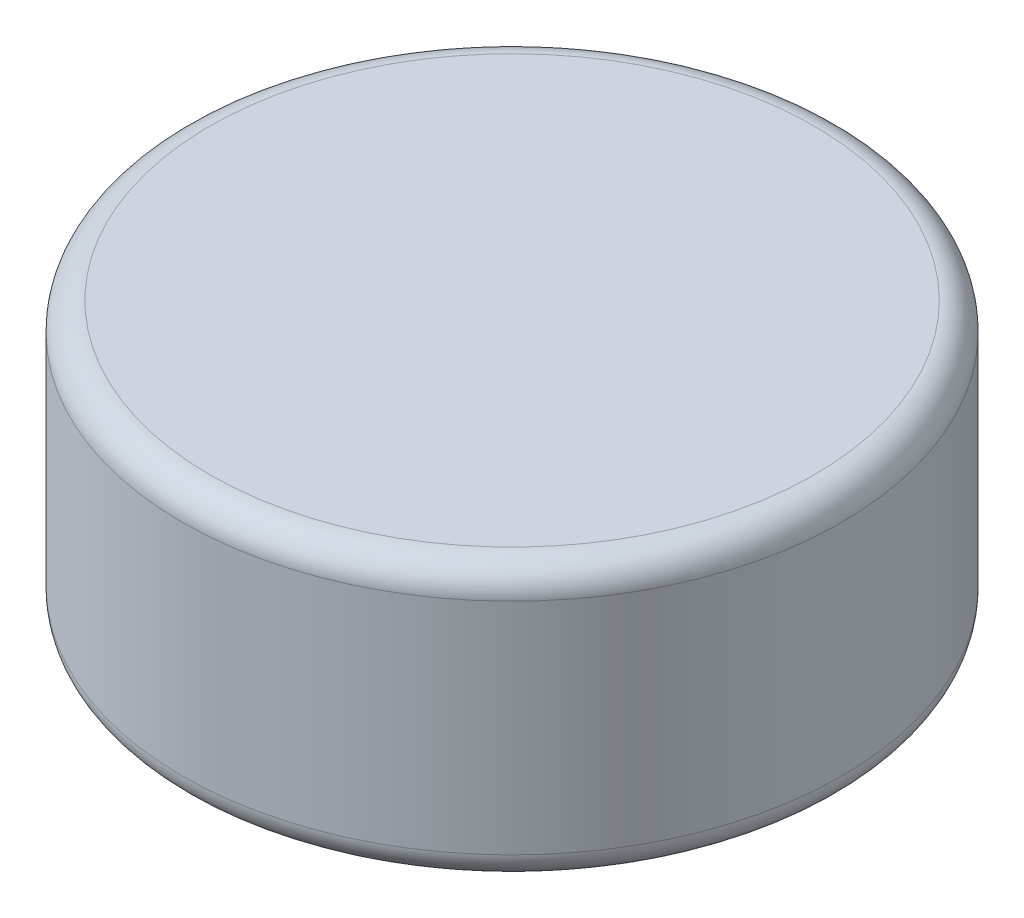
from build123d import *

# Parameters (mm, degrees)
SKETCH1_R           = 3
BOSS_EXTRUDE1_DEPTH = 2.5
FILLET1_R           = 0.25


with BuildPart() as part:
    # Sketch1 → Boss-Extrude1 (new body)
    with BuildSketch(Plane(origin=(0, 0, 0), x_dir=(1, 0, 0), z_dir=(0, 1, 0))):
        Circle(SKETCH1_R)
    extrude(amount=BOSS_EXTRUDE1_DEPTH)

    # Fillet1
    fillet1_edges = [part.edges().sort_by_distance(p)[0] for p in [
        (-3, 0, 0),
        (-3, 2.5, 0),
    ]]
    fillet(fillet1_edges, radius=FILLET1_R)


solid = part.part
